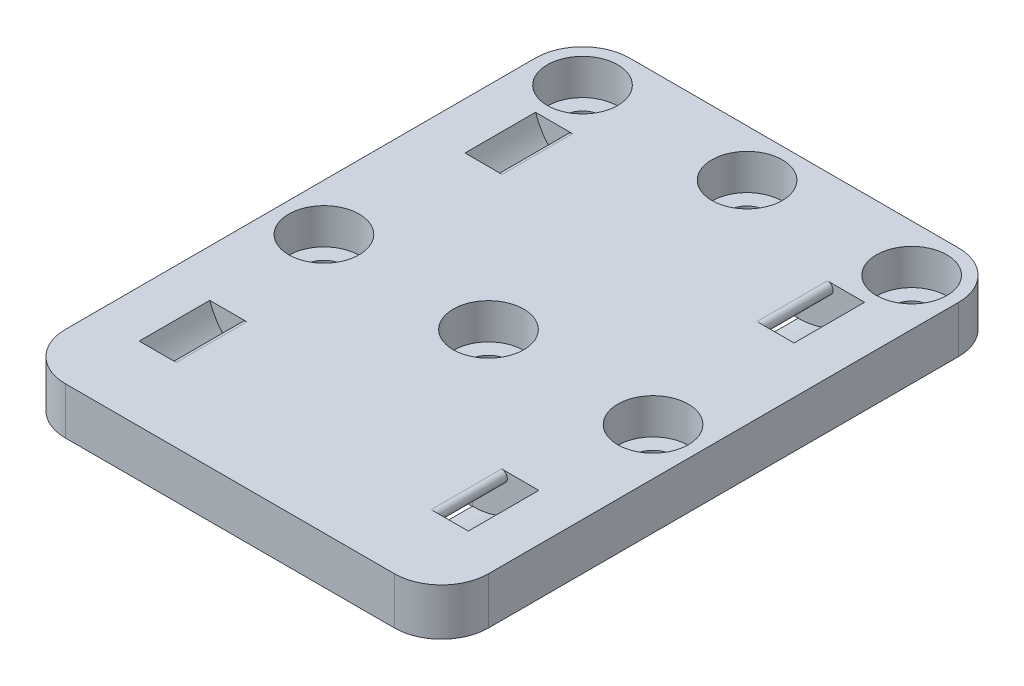
from build123d import *

# Parameters (mm, degrees)
BOSS_EXTRUDE1_DEPTH                             = 6.35
CBORE_FOR_10_SOCKET_HEAD_CAP_SCREW1_D           = 5.1054
CBORE_FOR_10_SOCKET_HEAD_CAP_SCREW1_CBORE_D     = 9.525
CBORE_FOR_10_SOCKET_HEAD_CAP_SCREW1_CBORE_DEPTH = 4.826
SKETCH5_W                                       = 9.525
SKETCH5_H                                       = 3.175
FILLET1_R                                       = 0.762


with BuildPart() as part:
    # Sketch1 → Boss-Extrude1 (new body)
    with BuildSketch(Plane(origin=(0, 0, 0), x_dir=(1, 0, 0), z_dir=(0, 1, 0))):
        with BuildLine():
            Line((22.225, -38.1), (-22.225, -38.1))
            ThreePointArc((-22.225, -38.1), (-26.715128061, -36.240128061), (-28.575, -31.75))
            Line((-28.575, -31.75), (-28.575, 31.75))
            ThreePointArc((-28.575, 31.75), (-26.715128061, 36.240128061), (-22.225, 38.1))
            Line((-22.225, 38.1), (22.225, 38.1))
            ThreePointArc((22.225, 38.1), (26.715128061, 36.240128061), (28.575, 31.75))
            Line((28.575, 31.75), (28.575, -31.75))
            ThreePointArc((28.575, -31.75), (26.715128061, -36.240128061), (22.225, -38.1))
        make_face()
    extrude(amount=BOSS_EXTRUDE1_DEPTH)

    # CBORE for #10 Socket Head Cap Screw1 (through all)
    with Locations(Plane(origin=(0, 6.35, 0), x_dir=(1, 0, 0), z_dir=(0, 1, 0))):
        with Locations((-22.225, 31.75), (0, 31.75), (22.225, 31.75), (0, -3.175), (22.225, -3.175), (-22.225, -3.175)):
            CounterBoreHole(CBORE_FOR_10_SOCKET_HEAD_CAP_SCREW1_D / 2, CBORE_FOR_10_SOCKET_HEAD_CAP_SCREW1_CBORE_D / 2, CBORE_FOR_10_SOCKET_HEAD_CAP_SCREW1_CBORE_DEPTH)

    # Cut-Sweep1: sweep along a path in Sketch6
    with BuildLine(Plane.XY) as cut_sweep1_path:
        ThreePointArc((22.225, 6.35), (18.744005193, 1.747870067), (13.244743879, 0))
        Line((13.244743879, 0), (-13.244743879, 0))
        ThreePointArc((-13.244743879, 0), (-18.744005193, 1.747870067), (-22.225, 6.35))
    # Sketch5 → Cut-Sweep1 (sweep, cut)
    with BuildSketch(Plane(origin=(0, 0, 0), x_dir=(0, 0, -1), z_dir=(1, 0, 0))):
        with Locations((20.6375, 1.5875)):
            Rectangle(SKETCH5_W, SKETCH5_H)
        with Locations((-23.3625, 1.5875)):
            Rectangle(SKETCH5_W, SKETCH5_H)
    sweep(path=cut_sweep1_path.line, mode=Mode.SUBTRACT)

    # Fillet1
    fillet1_edges = [part.edges().sort_by_distance(p)[0] for p in [
        (18.744005193, 6.35, 23.3625),
        (-18.744005193, 6.35, 23.3625),
        (18.744005193, 6.35, -20.6375),
        (-18.744005193, 6.35, -20.6375),
    ]]
    fillet(fillet1_edges, radius=FILLET1_R)


solid = part.part
